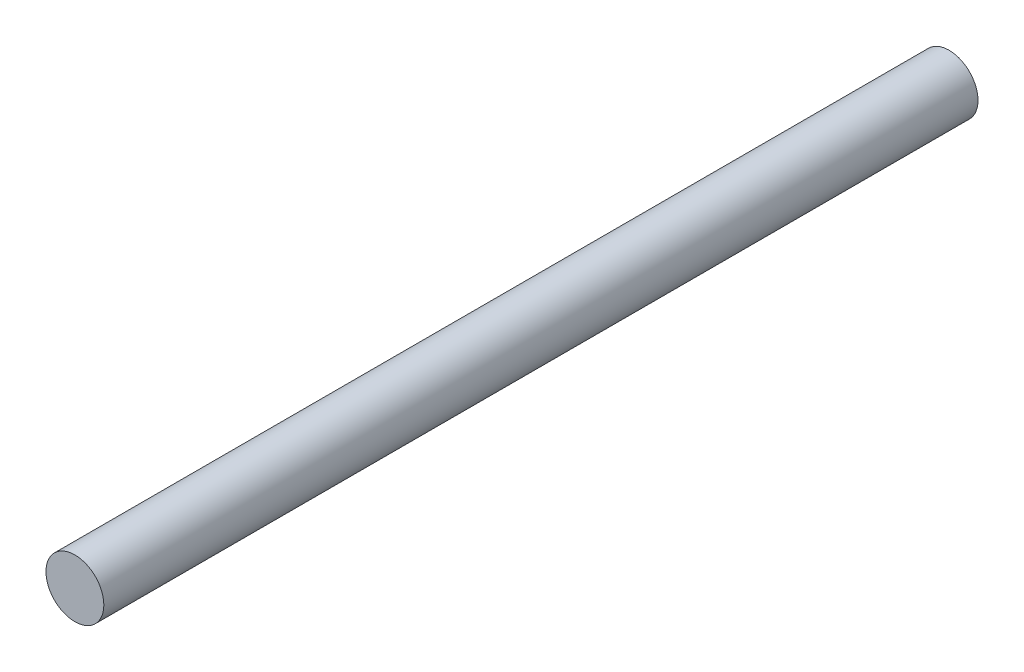
from build123d import *

# Parameters (mm, degrees)
SKETCH1_R           = 12.5
BOSS_EXTRUDE1_DEPTH = 365
SKETCH2_R           = 12.5
BOSS_EXTRUDE2_DEPTH = 12.5


with BuildPart() as part:
    # Sketch1 → Boss-Extrude1 (new body)
    with BuildSketch(Plane.XY):
        Circle(SKETCH1_R)
    extrude(amount=BOSS_EXTRUDE1_DEPTH)

    # Sketch2 → Boss-Extrude2 (add)
    with BuildSketch(Plane.XY.offset(365)):
        Circle(SKETCH2_R)
    extrude(amount=BOSS_EXTRUDE2_DEPTH)


solid = part.part
